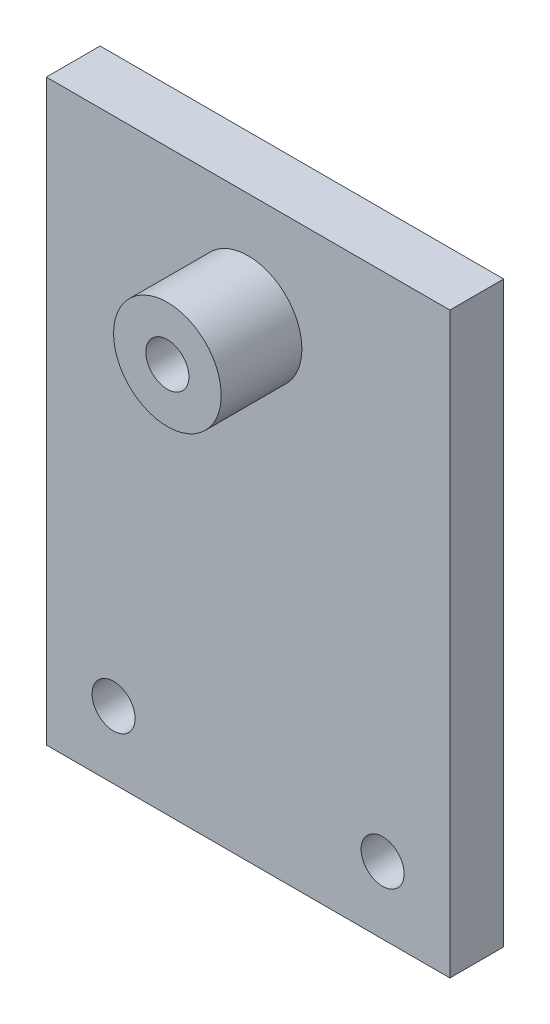
from build123d import *

# Parameters (mm, degrees)
SKETCH_1_W          = 30
SKETCH_1_H          = 43
SKETCH_1_R          = 1.6
SKETCH_1_R_2        = 4
EXTRUDE_1_DEPTH     = 4
EXTRUDE_START       = -4
SKETCH_2_R          = 4
EXTRUDE_2_DEPTH     = 10
SKETCH_3_R          = 1.6
CUT_EXTRUDE_1_DEPTH = 11


with BuildPart() as part:
    # 草图1 → 凸台-拉伸1 (new body)
    with BuildSketch(Plane.XY):
        with Locations((-15, 24.658548848)):
            Rectangle(SKETCH_1_W, SKETCH_1_H)
        with Locations((-5, 8.158548848)):
            Circle(SKETCH_1_R, mode=Mode.SUBTRACT)
        with Locations((-25, 8.158548848)):
            Circle(SKETCH_1_R, mode=Mode.SUBTRACT)
        with Locations((-15, 38.158548848)):
            Circle(SKETCH_1_R_2, mode=Mode.SUBTRACT)
    extrude(amount=EXTRUDE_1_DEPTH)

    # 草图2 → 凸台-拉伸2 (add)
    with BuildSketch(Plane.XY.offset(4).offset(EXTRUDE_START)):
        with Locations((-15, 38.158548848)):
            Circle(SKETCH_2_R)
    extrude(amount=EXTRUDE_2_DEPTH)

    # 草图3 → 切除-拉伸1 (cut, through all)
    with BuildSketch(Plane.XY.offset(10)):
        with Locations((-15, 38.158548848)):
            Circle(SKETCH_3_R)
    extrude(amount=-CUT_EXTRUDE_1_DEPTH, mode=Mode.SUBTRACT)


solid = part.part
